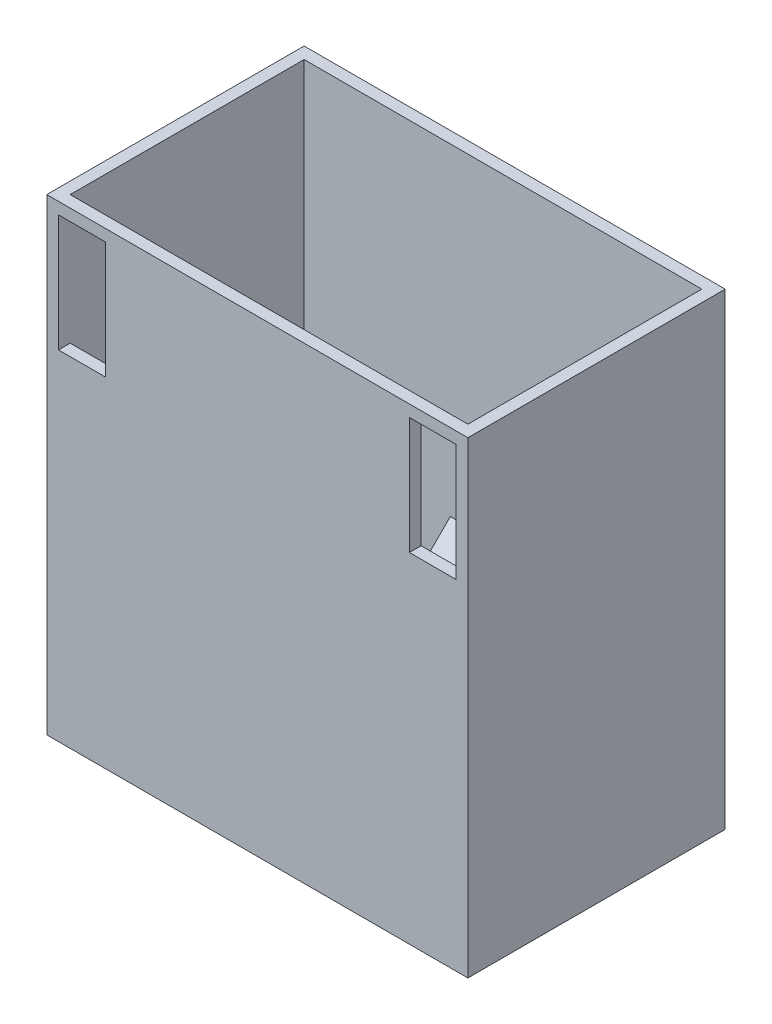
from build123d import *

# Parameters (mm, degrees)
SKETCH2_W                = 90
SKETCH2_H                = 55
BOSS_EXTRUDE1_DEPTH      = 100
SKETCH3_W                = 85
SKETCH3_H                = 50
CUT_EXTRUDE1_DEPTH       = 95
BOSS_EXTRUDE4_DEPTH      = 20
BOSS_EXTRUDE4_DEPTH_BACK = 2.5
SKETCH4_W                = 17.5
SKETCH4_H                = 30
SKETCH7_W                = 17.5
SKETCH7_H                = 2.5
CUT_EXTRUDE2_REACH       = 57
SKETCH11_W               = 10
SKETCH11_H               = 25


with BuildPart() as part:
    # Sketch2 → Boss-Extrude1 (new body)
    with BuildSketch(Plane(origin=(0, 0, 0), x_dir=(1, 0, 0), z_dir=(0, 1, 0))):
        with Locations((45, 27.5)):
            Rectangle(SKETCH2_W, SKETCH2_H)
    extrude(amount=BOSS_EXTRUDE1_DEPTH)

    # Sketch3 → Cut-Extrude1 (cut)
    with BuildSketch(Plane(origin=(0, 100, 0), x_dir=(1, 0, 0), z_dir=(0, 1, 0))):
        with Locations((45, 27.5)):
            Rectangle(SKETCH3_W, SKETCH3_H)
    extrude(amount=-CUT_EXTRUDE1_DEPTH, mode=Mode.SUBTRACT)

    # Sketch10 → Boss-Extrude4 (add, two sides)
    with BuildSketch(Plane(origin=(36.25, 0, 0), x_dir=(0, 0, -1), z_dir=(1, 0, 0))) as boss_extrude4_sk:
        Polygon((55, 30), (55, 0), (25, 0), (21.464466094, 0), (55, 33.535533906), align=None)
    extrude(amount=BOSS_EXTRUDE4_DEPTH)
    extrude(boss_extrude4_sk.sketch, amount=-BOSS_EXTRUDE4_DEPTH_BACK)

    # Sketch4 → Cut-Loft4 section 0
    with BuildSketch(Plane.XZ):
        with Locations((45, -40)):
            Rectangle(SKETCH4_W, SKETCH4_H)
    # Sketch7 → Cut-Loft4 section 1
    with BuildSketch(Plane(origin=(0, 30, 0), x_dir=(-1, 0, 0), z_dir=(0, -1, 0))):
        with Locations((-45, 53.75)):
            Rectangle(SKETCH7_W, SKETCH7_H)
    loft(mode=Mode.SUBTRACT)

    # Sketch11 → Cut-Extrude2 (cut, up to next)
    with BuildSketch(Plane.XY, mode=Mode.PRIVATE) as cut_extrude2_sk1:
        with Locations((82.5, 85)):
            Rectangle(SKETCH11_W, SKETCH11_H)
    cut_extrude2_tool1 = extrude(cut_extrude2_sk1.sketch, amount=-CUT_EXTRUDE2_REACH, mode=Mode.PRIVATE) & part.part
    add(cut_extrude2_tool1.solids().sort_by_distance((82.5, 85, 0))[0], mode=Mode.SUBTRACT)
    # Sketch11 → Cut-Extrude2 (cut, up to next)
    with BuildSketch(Plane.XY, mode=Mode.PRIVATE) as cut_extrude2_sk2:
        with Locations((7.5, 85)):
            Rectangle(SKETCH11_W, SKETCH11_H)
    cut_extrude2_tool2 = extrude(cut_extrude2_sk2.sketch, amount=-CUT_EXTRUDE2_REACH, mode=Mode.PRIVATE) & part.part
    add(cut_extrude2_tool2.solids().sort_by_distance((7.5, 85, 0))[0], mode=Mode.SUBTRACT)


solid = part.part
